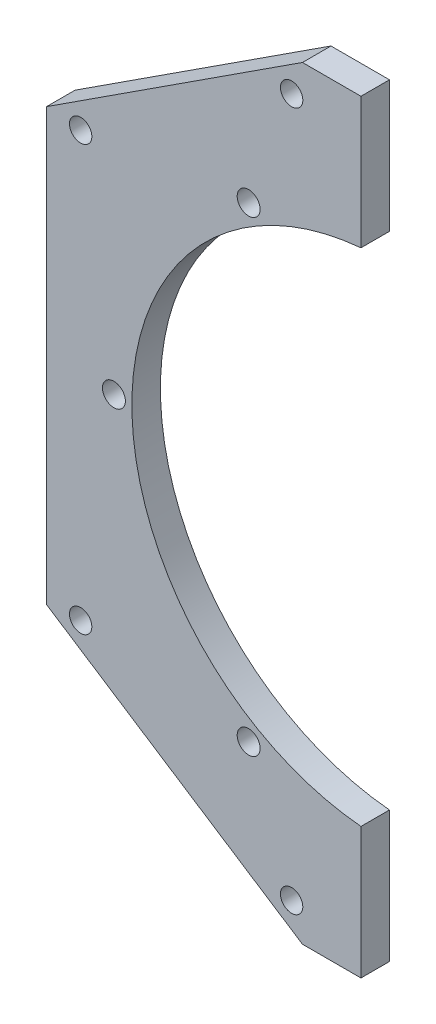
from build123d import *

# Parameters (mm, degrees)
BOSS_EXTRUDE1_DEPTH        = 6.35
F_10_CLEARANCE_HOLE1_D     = 4.9784
F_10_CLEARANCE_HOLE1_DEPTH = 135.89
F_10_CLEARANCE_HOLE1_TIP   = 1.495662253
SKETCH4_R                  = 56
CUT_EXTRUDE1_DEPTH         = 7.35
F_10_CLEARANCE_HOLE2_D     = 5.1054
CIRPATTERN1_COUNT          = 3
CIRPATTERN1_ANGLE          = 120


with BuildPart() as part:
    # Sketch1 → Boss-Extrude1 (new body)
    with BuildSketch(Plane.XY):
        Polygon((-75, 48), (-18.024996339, 85), (-5, 85), (-5, 0), (-75, 0), align=None)
    extrude(amount=BOSS_EXTRUDE1_DEPTH)

    # #10 Clearance Hole1
    with Locations(Plane(origin=(0, 0, 0), x_dir=(-1, 0, 0), z_dir=(0, 0, -1))):
        with Locations((20.435878863, 77.755724401), (67.401430668, 47.25593844)):
            Hole(F_10_CLEARANCE_HOLE1_D / 2, depth=F_10_CLEARANCE_HOLE1_DEPTH)
            with Locations((0, 0, -(F_10_CLEARANCE_HOLE1_DEPTH + F_10_CLEARANCE_HOLE1_TIP / 2))):  # 118° drill point
                Cone(0, F_10_CLEARANCE_HOLE1_D / 2, F_10_CLEARANCE_HOLE1_TIP, mode=Mode.SUBTRACT)

    # Sketch4 → Cut-Extrude1 (cut, through all)
    with BuildSketch(Plane(origin=(0, 0, 0), x_dir=(-1, 0, 0), z_dir=(0, 0, -1))):
        Circle(SKETCH4_R)
    extrude(amount=-CUT_EXTRUDE1_DEPTH, mode=Mode.SUBTRACT)

    # Mirror1: part across plane


with BuildPart() as part_1:
    add(part.part)
    add(part.part.mirror(Plane.ZX))

    # #10 Clearance Hole2 (through all)
    with Locations(Plane.XY.offset(6.35)):
        with Locations((-30, 51.961524227)):
            f_10_clearance_hole2 = Hole(F_10_CLEARANCE_HOLE2_D / 2)

    # CirPattern1: #10 Clearance Hole2 ×3 about axis
    cirpattern1_axis = Axis((0, 0, 0), (0, 0, 1))
    for i in range(1, CIRPATTERN1_COUNT):
        add(f_10_clearance_hole2.rotate(cirpattern1_axis, i * CIRPATTERN1_ANGLE / (CIRPATTERN1_COUNT - 1)), mode=Mode.SUBTRACT)


solid = part_1.part
